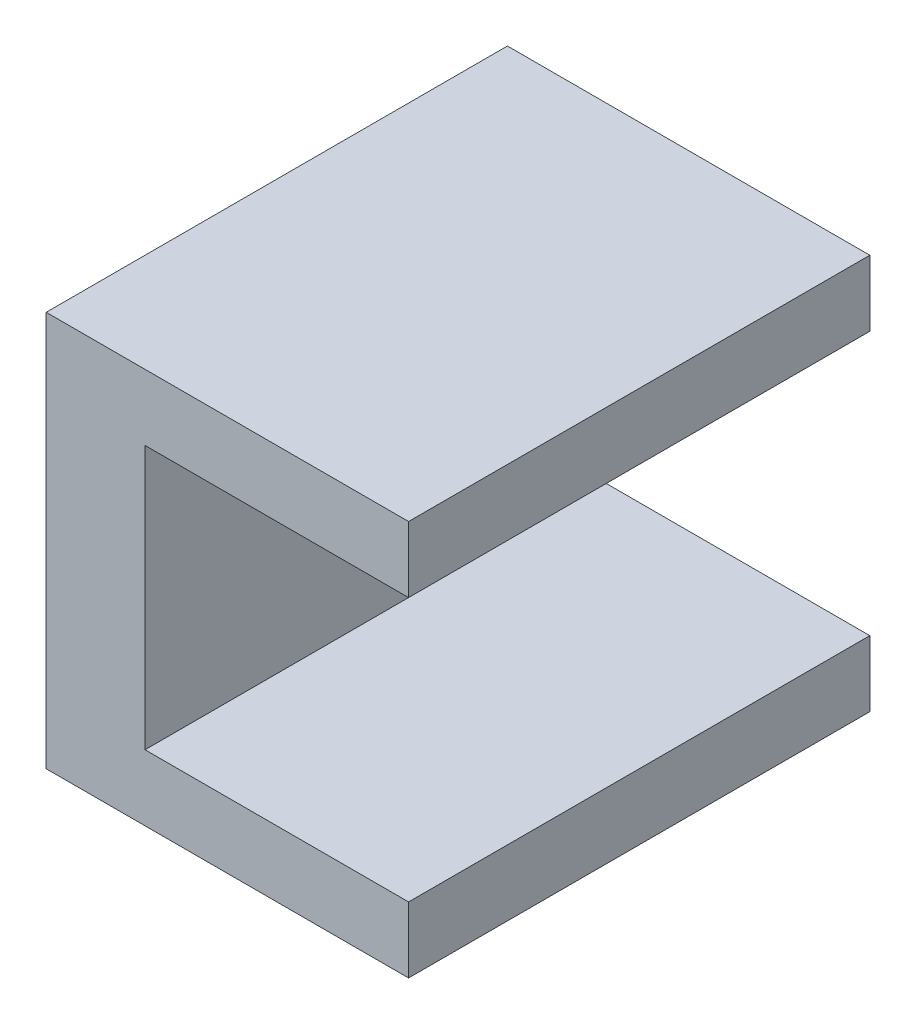
from build123d import *

# Parameters (mm, degrees)
SKETCH1_W           = 4.7625
SKETCH1_H           = 22.225
BOSS_EXTRUDE1_DEPTH = 3.175
SKETCH2_W           = 4.7625
SKETCH2_H           = 22.225
BOSS_EXTRUDE2_DEPTH = 15.875
SKETCH3_R           = 1
CUT_EXTRUDE1_DEPTH  = 5.7625
SKETCH5_W           = 22.225
SKETCH5_H           = 3.175
BOSS_EXTRUDE3_DEPTH = 12.7


with BuildPart() as part:
    # Sketch1 → Boss-Extrude1 (new body)
    with BuildSketch(Plane(origin=(0, 0, 0), x_dir=(1, 0, 0), z_dir=(0, 1, 0))):
        Rectangle(SKETCH1_W, SKETCH1_H)
    extrude(amount=BOSS_EXTRUDE1_DEPTH)

    # Sketch2 → Boss-Extrude2 (add)
    with BuildSketch(Plane(origin=(0, 3.175, 0), x_dir=(1, 0, 0), z_dir=(0, 1, 0))):
        Rectangle(SKETCH2_W, SKETCH2_H)
    extrude(amount=BOSS_EXTRUDE2_DEPTH)

    # Sketch3 → Cut-Extrude1 (cut, through all)
    with BuildSketch(Plane.ZY.offset(2.38125)):
        with Locations((3.175, 11.1125)):
            Circle(SKETCH3_R)
        with Locations((-3.175, 11.1125)):
            Circle(SKETCH3_R)
    extrude(amount=-CUT_EXTRUDE1_DEPTH, mode=Mode.SUBTRACT)

    # Sketch5 → Boss-Extrude3 (add)
    with BuildSketch(Plane(origin=(2.38125, 0, 0), x_dir=(0, 0, -1), z_dir=(1, 0, 0))):
        with Locations((0, 17.4625)):
            Rectangle(SKETCH5_W, SKETCH5_H)
        with Locations((0, 1.5875)):
            Rectangle(SKETCH5_W, SKETCH5_H)
    extrude(amount=BOSS_EXTRUDE3_DEPTH)


solid = part.part
